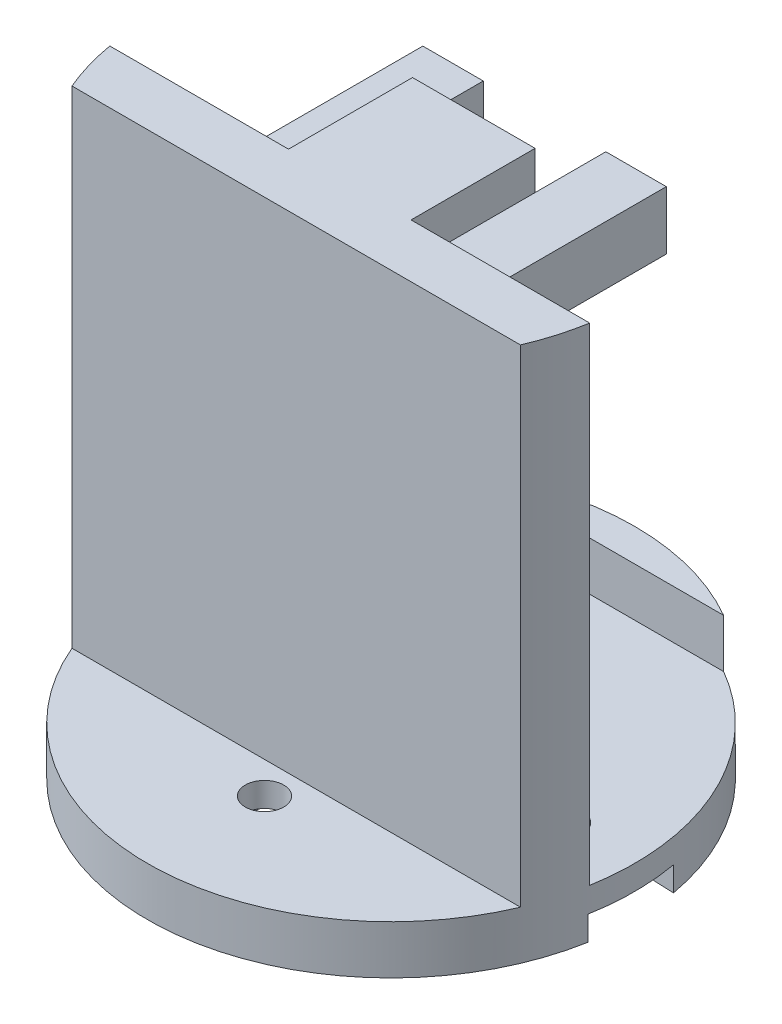
from build123d import *

# Parameters (mm, degrees)
SKETCH1_R           = 12.7
BOSS_EXTRUDE1_DEPTH = 2.54
BOSS_EXTRUDE2_DEPTH = 25.4
BOSS_EXTRUDE3_REACH = 19.018
SKETCH3_W           = 6.393920166
SKETCH3_H           = 6.393920167
SKETCH4_R           = 1.397
CUT_EXTRUDE1_DEPTH  = 5.588
CUT_EXTRUDE2_REACH  = 29.94
SKETCH6_R           = 1
CUT_EXTRUDE4_DEPTH  = 1.27
SKETCH10_W          = 3.153039917
SKETCH10_H          = 3.048
BOSS_EXTRUDE4_DEPTH = 10.16
CHAMFER1_SIZE       = 1.27
BOSS_EXTRUDE5_DEPTH = 2.54


with BuildPart() as part:
    # Sketch1 → Boss-Extrude1 (new body)
    with BuildSketch(Plane(origin=(0, 0, 0), x_dir=(1, 0, 0), z_dir=(0, 1, 0))):
        Circle(SKETCH1_R)
    extrude(amount=BOSS_EXTRUDE1_DEPTH)

    # Sketch2 → Boss-Extrude2 (add)
    with BuildSketch(Plane(origin=(0, 2.54, 0), x_dir=(1, 0, 0), z_dir=(0, 1, 0))):
        with BuildLine():
            Line((12.516478449, -2.151224589), (-12.516478449, -2.151224589))
            ThreePointArc((-12.516478449, -2.151224589), (-12.187390109, -3.571767395), (-11.697638811, -4.945224589))
            Line((-11.697638811, -4.945224589), (11.697638811, -4.945224589))
            ThreePointArc((11.697638811, -4.945224589), (12.187390109, -3.571767395), (12.516478449, -2.151224589))
        make_face()
    extrude(amount=BOSS_EXTRUDE2_DEPTH)

    # Sketch3 → Boss-Extrude3 (add, up to next)
    with BuildSketch(Plane(origin=(0, 0, -4.318), x_dir=(-1, 0, 0), z_dir=(0, 0, -1)), mode=Mode.PRIVATE) as boss_extrude3_sk1:
        with Locations((0, 24.743039917)):
            Rectangle(SKETCH3_W, SKETCH3_H)
    boss_extrude3_tool1 = extrude(boss_extrude3_sk1.sketch, amount=-BOSS_EXTRUDE3_REACH, mode=Mode.PRIVATE) - part.part
    add(boss_extrude3_tool1.solids().sort_by_distance((0, 24.74304, -4.318))[0])

    # Sketch4 → Cut-Extrude1 (cut)
    with BuildSketch(Plane(origin=(0, 0, -4.318), x_dir=(-1, 0, 0), z_dir=(0, 0, -1))):
        with Locations((0, 24.743039917)):
            Circle(SKETCH4_R)
    extrude(amount=-CUT_EXTRUDE1_DEPTH, mode=Mode.SUBTRACT)

    # Sketch6 → Cut-Extrude2 (cut, up to next)
    with BuildSketch(Plane.XZ, mode=Mode.PRIVATE) as cut_extrude2_sk1:
        with Locations((9, 0)):
            Circle(SKETCH6_R)
    cut_extrude2_tool1 = extrude(cut_extrude2_sk1.sketch, amount=-CUT_EXTRUDE2_REACH, mode=Mode.PRIVATE) & part.part
    add(cut_extrude2_tool1.solids().sort_by_distance((9, 0, 0))[0], mode=Mode.SUBTRACT)
    # Sketch6 → Cut-Extrude2 (cut, up to next)
    with BuildSketch(Plane.XZ, mode=Mode.PRIVATE) as cut_extrude2_sk2:
        with Locations((0, -6.6)):
            Circle(SKETCH6_R)
    cut_extrude2_tool2 = extrude(cut_extrude2_sk2.sketch, amount=-CUT_EXTRUDE2_REACH, mode=Mode.PRIVATE) & part.part
    add(cut_extrude2_tool2.solids().sort_by_distance((0, 0, -6.6))[0], mode=Mode.SUBTRACT)
    # Sketch6 → Cut-Extrude2 (cut, up to next)
    with BuildSketch(Plane.XZ, mode=Mode.PRIVATE) as cut_extrude2_sk3:
        with Locations((-9, 0)):
            Circle(SKETCH6_R)
    cut_extrude2_tool3 = extrude(cut_extrude2_sk3.sketch, amount=-CUT_EXTRUDE2_REACH, mode=Mode.PRIVATE) & part.part
    add(cut_extrude2_tool3.solids().sort_by_distance((-9, 0, 0))[0], mode=Mode.SUBTRACT)
    # Sketch6 → Cut-Extrude2 (cut, up to next)
    with BuildSketch(Plane.XZ, mode=Mode.PRIVATE) as cut_extrude2_sk4:
        with Locations((0, 6.6)):
            Circle(SKETCH6_R)
    cut_extrude2_tool4 = extrude(cut_extrude2_sk4.sketch, amount=-CUT_EXTRUDE2_REACH, mode=Mode.PRIVATE) & part.part
    add(cut_extrude2_tool4.solids().sort_by_distance((0, 0, 6.6))[0], mode=Mode.SUBTRACT)
    # Sketch6 → Cut-Extrude2 (cut, up to next)
    with BuildSketch(Plane.XZ, mode=Mode.PRIVATE) as cut_extrude2_sk5:
        Circle(SKETCH6_R)
    cut_extrude2_tool5 = extrude(cut_extrude2_sk5.sketch, amount=-CUT_EXTRUDE2_REACH, mode=Mode.PRIVATE) & part.part
    add(cut_extrude2_tool5.solids().sort_by_distance((0, 0, 0))[0], mode=Mode.SUBTRACT)

    # Sketch9 → Cut-Extrude4 (cut)
    with BuildSketch(Plane.XZ):
        with BuildLine():
            Line((-2.1, -6.6), (-2.1, -3.046309242))
            ThreePointArc((-2.1, -3.046309242), (-2.376743942, -2.835681264), (-2.632489316, -2.6))
            Line((-2.632489316, -2.6), (-3.60208243, -2.6))
            Line((-3.60208243, -2.6), (-15.602107818, -2.099998942))
            ThreePointArc((-15.602107818, -2.099998942), (-17.7, 0), (-15.602107818, 2.099998942))
            Line((-15.602107818, 2.099998942), (-3.60208243, 2.6))
            Line((-3.60208243, 2.6), (-2.632489316, 2.6))
            ThreePointArc((-2.632489316, 2.6), (-2.376743942, 2.835681264), (-2.1, 3.046309242))
            Line((-2.1, 3.046309242), (-2.1, 6.6))
            ThreePointArc((-2.1, 6.6), (0, 8.7), (2.1, 6.6))
            Line((2.1, 6.6), (2.1, 3.046309242))
            ThreePointArc((2.1, 3.046309242), (2.376743942, 2.835681264), (2.632489316, 2.6))
            Line((2.632489316, 2.6), (3.60208243, 2.6))
            Line((3.60208243, 2.6), (15.602107818, 2.099998942))
            ThreePointArc((15.602107818, 2.099998942), (17.7, 0), (15.602107818, -2.099998942))
            Line((15.602107818, -2.099998942), (3.60208243, -2.6))
            Line((3.60208243, -2.6), (2.632489316, -2.6))
            ThreePointArc((2.632489316, -2.6), (2.376743942, -2.835681264), (2.1, -3.046309242))
            Line((2.1, -3.046309242), (2.1, -6.6))
            ThreePointArc((2.1, -6.6), (0, -8.7), (-2.1, -6.6))
        make_face()
    extrude(amount=-CUT_EXTRUDE4_DEPTH, mode=Mode.SUBTRACT)

    # Sketch10 → Boss-Extrude4 (add)
    with BuildSketch(Plane(origin=(0, 0, 2.151224589), x_dir=(-1, 0, 0), z_dir=(0, 0, -1))):
        with Locations((-4.773480042, 24.416)):
            Rectangle(SKETCH10_W, SKETCH10_H)
        with Locations((4.773480042, 24.416)):
            Rectangle(SKETCH10_W, SKETCH10_H)
    extrude(amount=BOSS_EXTRUDE4_DEPTH)

    # Chamfer1
    chamfer1_edges = [part.edges().sort_by_distance(p)[0] for p in [
        (4.773480042, 22.892, 2.151224589),
        (-4.773480042, 22.892, 2.151224589),
        (0, 21.546079833, 2.151224589),
    ]]
    chamfer(chamfer1_edges, length=CHAMFER1_SIZE)

    # Sketch11 → Boss-Extrude5 (add)
    with BuildSketch(Plane(origin=(0, 2.54, 0), x_dir=(1, 0, 0), z_dir=(0, 1, 0))):
        with BuildLine():
            Line((-6.35, 10.998522628), (6.35, 10.998522628))
            ThreePointArc((6.35, 10.998522628), (0, 12.7), (-6.35, 10.998522628))
        make_face()
    extrude(amount=BOSS_EXTRUDE5_DEPTH)


solid = part.part
